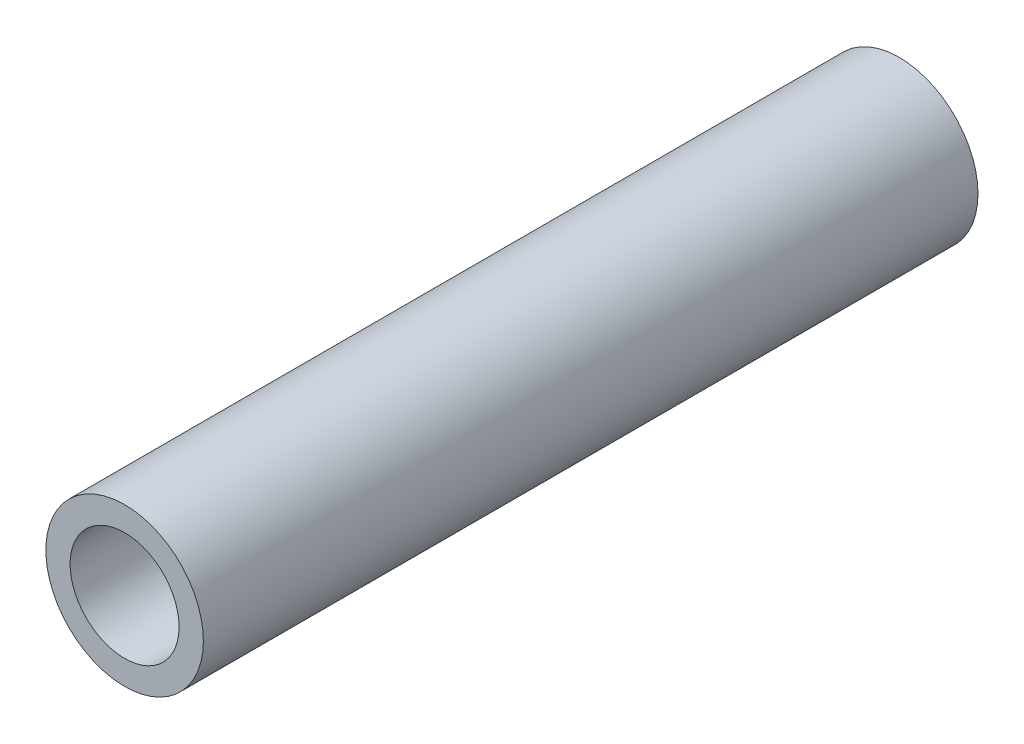
from build123d import *

# Parameters (mm, degrees)
SKETCH1_R           = 7.747
SKETCH1_R_2         = 5.3594
BOSS_EXTRUDE1_DEPTH = 76.2


with BuildPart() as part:
    # Sketch1 → Boss-Extrude1 (new body)
    with BuildSketch(Plane.XY):
        Circle(SKETCH1_R)
        Circle(SKETCH1_R_2, mode=Mode.SUBTRACT)
    extrude(amount=BOSS_EXTRUDE1_DEPTH)


solid = part.part
